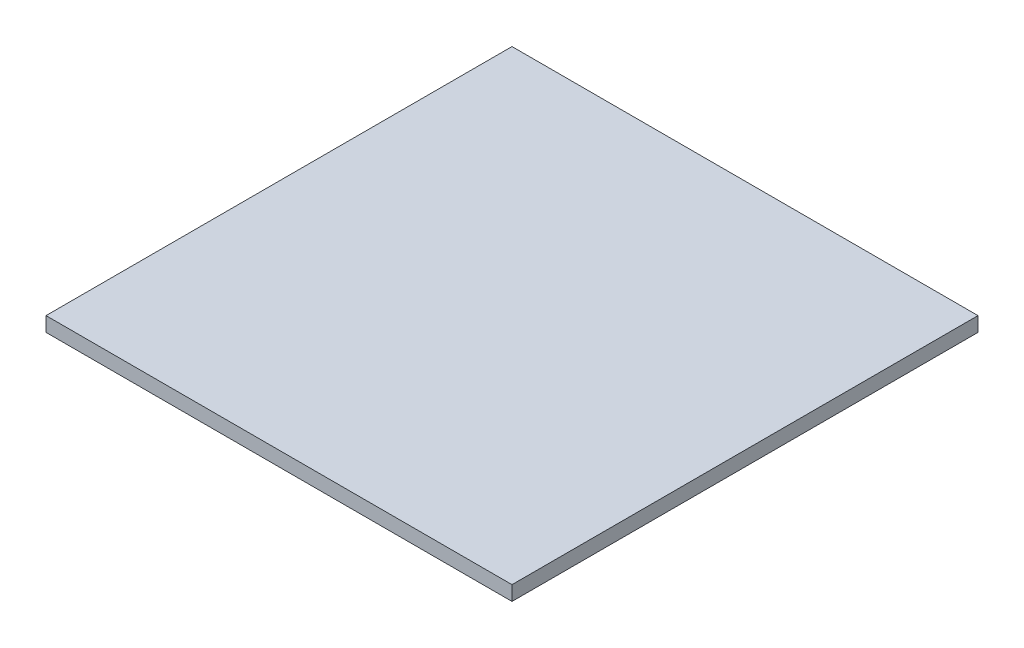
from build123d import *

# Parameters (mm, degrees)
SKETCH1_W           = 101.6
SKETCH1_H           = 101.6
BOSS_EXTRUDE1_DEPTH = 3.175


with BuildPart() as part:
    # Sketch1 → Boss-Extrude1 (new body)
    with BuildSketch(Plane(origin=(0, 0, 0), x_dir=(1, 0, 0), z_dir=(0, 1, 0))):
        with Locations((50.8, 50.8)):
            Rectangle(SKETCH1_W, SKETCH1_H)
    extrude(amount=BOSS_EXTRUDE1_DEPTH)


solid = part.part
